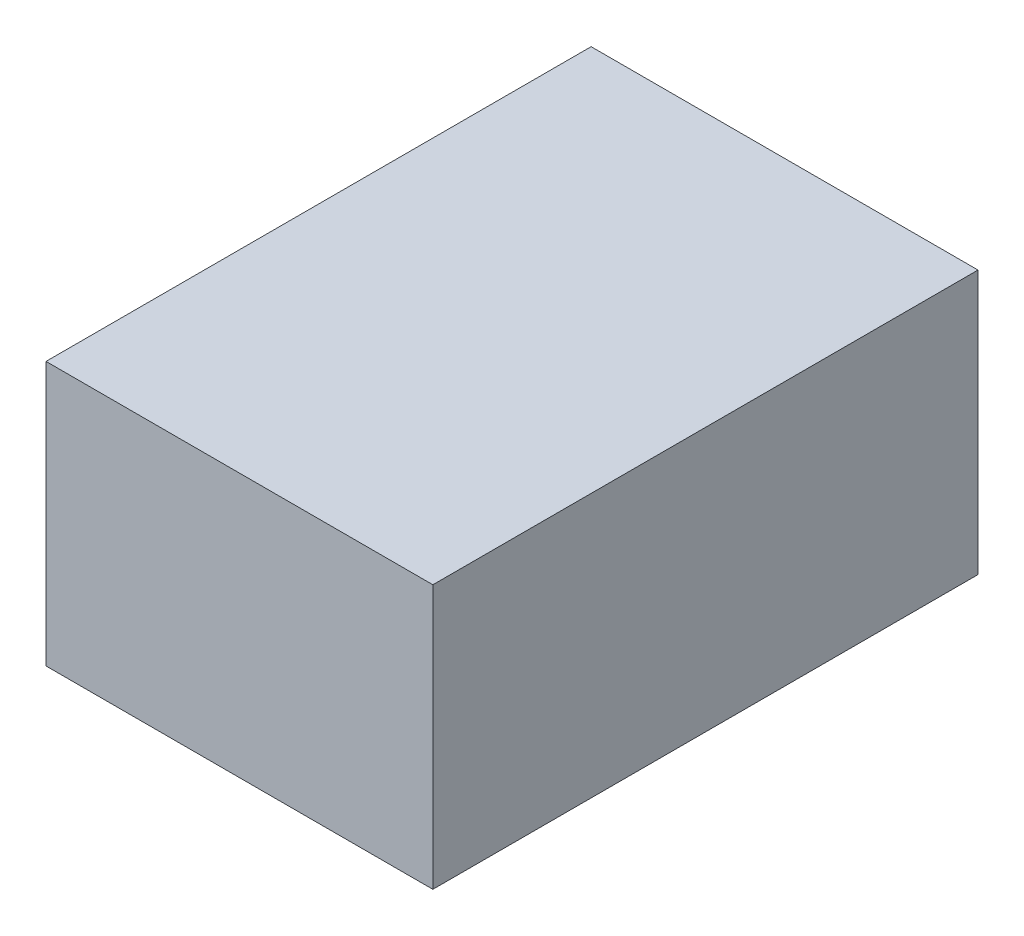
from build123d import *

# Parameters (mm, degrees)
ESQUISSE1_W        = 44
ESQUISSE1_H        = 62
BOSS_EXTRU_1_DEPTH = 30


with BuildPart() as part:
    # Esquisse1 → Boss.-Extru.1 (new body)
    with BuildSketch(Plane(origin=(0, 0, 0), x_dir=(1, 0, 0), z_dir=(0, 1, 0))):
        Rectangle(ESQUISSE1_W, ESQUISSE1_H)
    extrude(amount=BOSS_EXTRU_1_DEPTH)


solid = part.part
